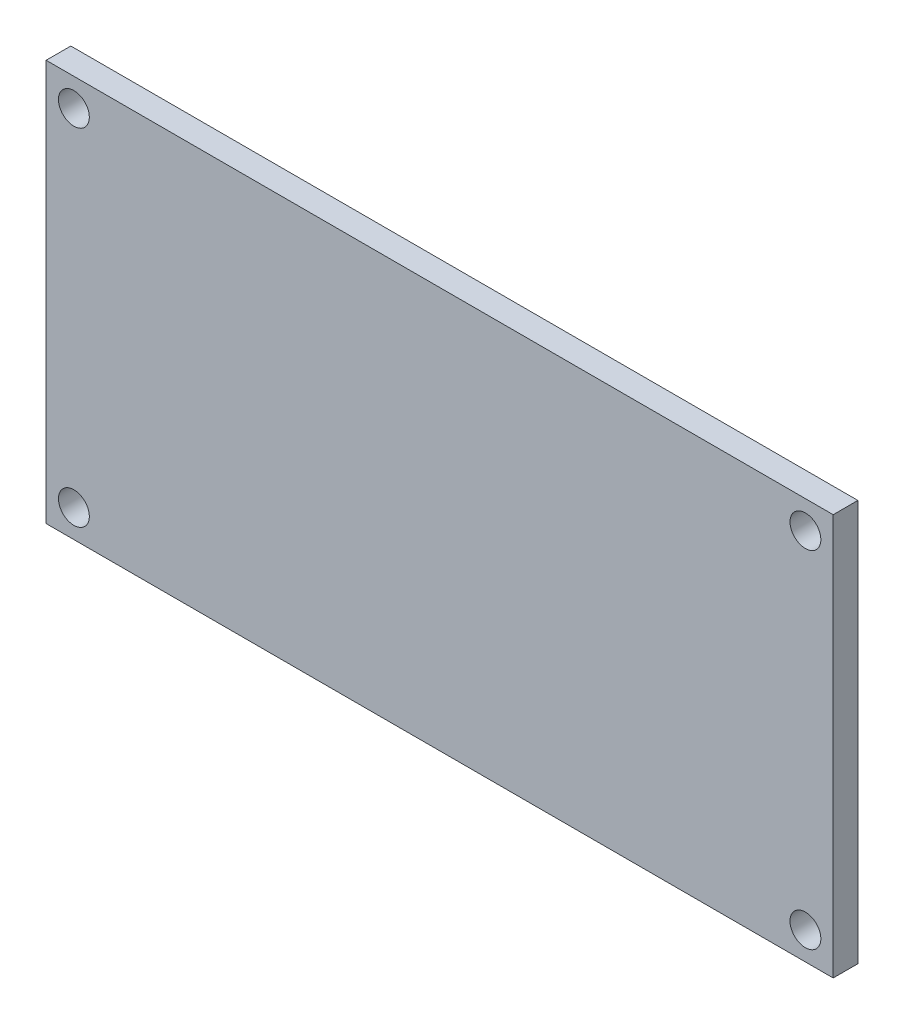
from build123d import *

# Parameters (mm, degrees)
SKETCH1_W           = 51
SKETCH1_H           = 26
SKETCH1_R           = 1
BOSS_EXTRUDE1_DEPTH = 1.6


with BuildPart() as part:
    # Sketch1 → Boss-Extrude1 (new body)
    with BuildSketch(Plane.XY):
        Rectangle(SKETCH1_W, SKETCH1_H)
        with Locations((-23.7, 11.2)):
            Circle(SKETCH1_R, mode=Mode.SUBTRACT)
        with Locations((-23.7, -11.2)):
            Circle(SKETCH1_R, mode=Mode.SUBTRACT)
        with Locations((23.7, -11.2)):
            Circle(SKETCH1_R, mode=Mode.SUBTRACT)
        with Locations((23.7, 11.2)):
            Circle(SKETCH1_R, mode=Mode.SUBTRACT)
    extrude(amount=BOSS_EXTRUDE1_DEPTH)


solid = part.part
